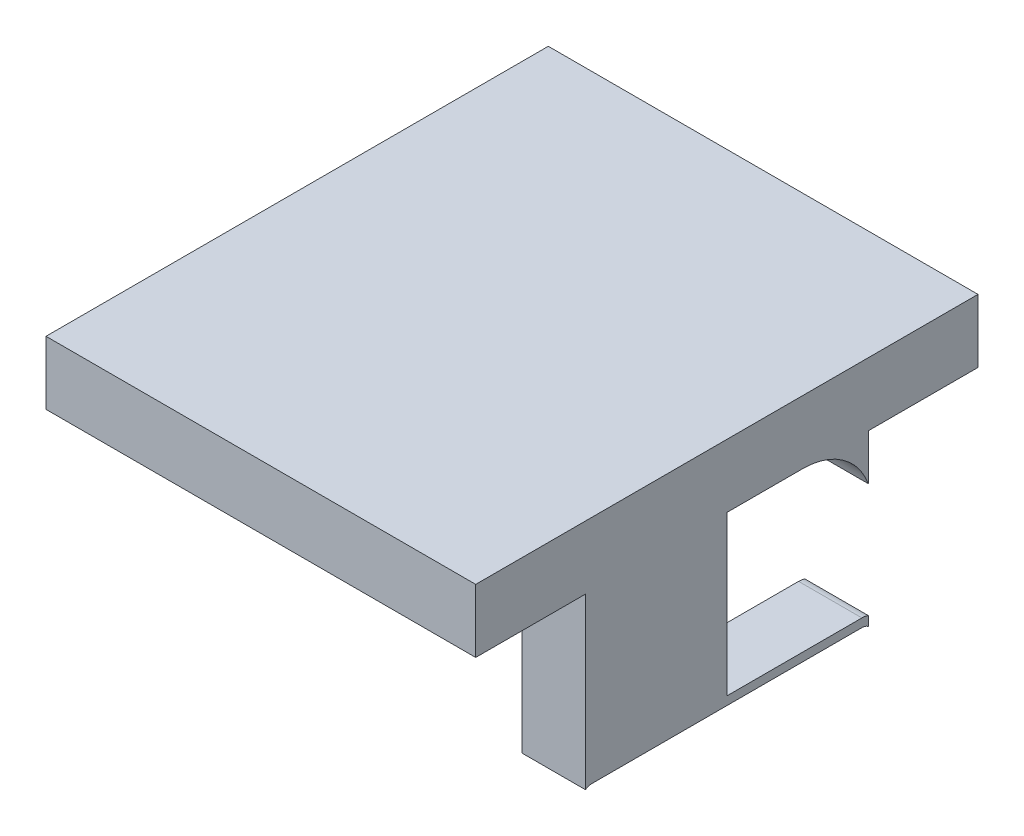
from build123d import *

# Parameters (mm, degrees)
BOSS_EXTRUDE1_DEPTH = 1.5
BOSS_EXTRUDE2_DEPTH = 10.18
SKETCH2_W           = 2.5
SKETCH2_H           = 0.9
SKETCH2_W_2         = 0.1
BOSS_EXTRUDE3_DEPTH = 1


with BuildPart() as part:
    # Sketch1 → Boss-Extrude1 (new body)
    with BuildSketch(Plane(origin=(-157.854562907, 0, 0), x_dir=(0, 0, -1), z_dir=(1, 0, 0))):
        with BuildLine():
            Line((30.880645232, -65.123367101), (30.880645232, -66.623367101))
            Line((30.880645232, -66.623367101), (33.480645232, -66.623367101))
            Line((33.480645232, -66.623367101), (33.480645232, -70.636755446))
            ThreePointArc((33.480645232, -70.636755446), (33.551588291, -70.599584622), (33.630645232, -70.586755446))
            Line((33.630645232, -70.586755446), (40.030645232, -70.586755446))
            ThreePointArc((40.030645232, -70.586755446), (40.109702174, -70.599584622), (40.180645232, -70.636755446))
            Line((40.180645232, -70.636755446), (40.180645232, -70.412491378))
            ThreePointArc((40.180645232, -70.412491378), (40.106741123, -70.393236094), (40.030645232, -70.386755446))
            Line((40.030645232, -70.386755446), (36.830645232, -70.386755446))
            Line((36.830645232, -70.386755446), (36.830645232, -66.623367101))
            Line((36.830645232, -66.623367101), (38.630645232, -66.623367101))
            ThreePointArc((38.630645232, -66.623367101), (39.576456801, -66.921353611), (40.180645232, -67.707681676))
            Line((40.180645232, -67.707681676), (40.180645232, -66.623367101))
            Line((40.180645232, -66.623367101), (42.780645232, -66.623367101))
            Line((42.780645232, -66.623367101), (42.780645232, -65.123367101))
            Line((42.780645232, -65.123367101), (30.880645232, -65.123367101))
        make_face()
    extrude(amount=-BOSS_EXTRUDE1_DEPTH)

    # Sketch1_3 → Boss-Extrude2 (add)
    with BuildSketch(Plane(origin=(-157.854562907, 0, 0), x_dir=(0, 0, -1), z_dir=(1, 0, 0))):
        Polygon((30.880645232, -65.123367101), (30.880645232, -66.623367101), (33.380645232, -66.623367101), (33.480645232, -66.623367101), (38.630645232, -66.623367101), (40.180645232, -66.623367101), (40.280645232, -66.623367101), (42.780645232, -66.623367101), (42.780645232, -65.123367101), align=None)
    extrude(amount=-BOSS_EXTRUDE2_DEPTH)

    # Sketch2 → Boss-Extrude3 (add)
    with BuildSketch(Plane.XZ.offset(66.623367101)):
        Polygon((-167.184562907, -32.480645232), (-167.184562907, -34.980645232), (-166.184562907, -34.980645232), (-166.184562907, -33.480645232), (-164.684562907, -33.480645232), (-164.684562907, -32.480645232), align=None)
        with Locations((-160.704562907, -40.730645232)):
            Rectangle(SKETCH2_W, SKETCH2_H)
        with Locations((-159.404562907, -40.730645232)):
            Rectangle(SKETCH2_W_2, SKETCH2_H)
    extrude(amount=BOSS_EXTRUDE3_DEPTH)


solid = part.part
